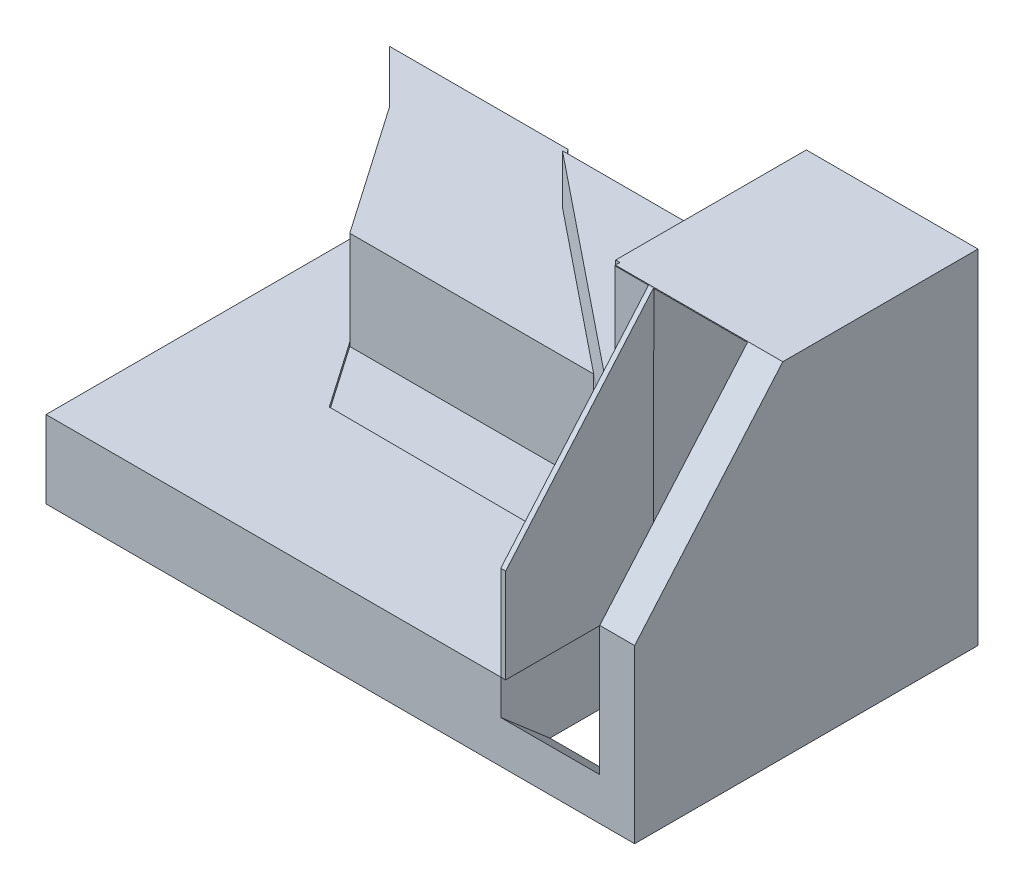
from build123d import *

# Parameters (mm, degrees)
SKETCH1_W           = 120
SKETCH1_H           = 70
BOSS_EXTRUDE1_DEPTH = 70
CUT_EXTRUDE1_DEPTH  = 150
SKETCH5_W           = 20.177747719
SKETCH5_H           = 66.048531366
CUT_EXTRUDE3_DEPTH  = 150
CUT_EXTRUDE4_DEPTH  = 25
CUT_EXTRUDE5_DEPTH  = 35
BOSS_EXTRUDE2_DEPTH = 35
CUT_EXTRUDE6_DEPTH  = 55
SKETCH14_W          = 58.303279042
SKETCH14_H          = 35.625039804
CUT_EXTRUDE7_DEPTH  = 1
BOSS_EXTRUDE5_DEPTH = 1
CUT_EXTRUDE9_DEPTH  = 20
CUT_EXTRUDE10_DEPTH = 20


with BuildPart() as part:
    # Sketch1 → Boss-Extrude1 (new body)
    with BuildSketch(Plane.XY):
        with Locations((10.120481928, 29.21686747)):
            Rectangle(SKETCH1_W, SKETCH1_H)
    extrude(amount=BOSS_EXTRUDE1_DEPTH)

    # Sketch3 → Cut-Extrude1 (cut)
    with BuildSketch(Plane(origin=(70.120481928, 0, 0), x_dir=(0, 0, -1), z_dir=(1, 0, 0))):
        Polygon((-39.794288679, 64.21686747), (-70, 29.21686747), (-70, 64.21686747), align=None)
    extrude(amount=-CUT_EXTRUDE1_DEPTH, mode=Mode.SUBTRACT)

    # Sketch5 → Cut-Extrude3 (cut)
    with BuildSketch(Plane(origin=(0, 47.095410713, 54.570453827), x_dir=(1, 0, 0), z_dir=(0, 0.653352699, 0.757053665))):
        with Locations((52.91919907, -10.542758773)):
            Rectangle(SKETCH5_W, SKETCH5_H)
    extrude(amount=-CUT_EXTRUDE3_DEPTH, mode=Mode.SUBTRACT)

    # Sketch6 → Cut-Extrude4 (cut)
    with BuildSketch(Plane(origin=(0, 64.21686747, 0), x_dir=(1, 0, 0), z_dir=(0, 1, 0))):
        Polygon((35.120481928, 0), (-14.879518072, 0), (35.120481928, -40), align=None)
    extrude(amount=-CUT_EXTRUDE4_DEPTH, mode=Mode.SUBTRACT)

    # Sketch9 → Cut-Extrude5 (cut)
    with BuildSketch(Plane(origin=(0, 64.21686747, 0), x_dir=(1, 0, 0), z_dir=(0, 1, 0))):
        Polygon((12.260999006, -39.794288679), (-22.324601561, -39.794288679), (-49.879518072, 0), (-58.507323934, 12.460113859), (-30.081695552, 12.460113859), (34.863342776, -39.794288679), align=None)
    extrude(amount=-CUT_EXTRUDE5_DEPTH, mode=Mode.SUBTRACT)

    # Sketch10 → Boss-Extrude2 (add)
    with BuildSketch(Plane(origin=(0, 29.21686747, 0), x_dir=(1, 0, 0), z_dir=(0, 1, 0))):
        Polygon((-49.879518072, 0), (-60.681640724, 10.802122652), (-24.289355103, 10.802122652), (-14.595487063, 0), align=None)
    extrude(amount=-BOSS_EXTRUDE2_DEPTH)

    # Sketch13 → Cut-Extrude6 (cut)
    with BuildSketch(Plane(origin=(0, 65, 0), x_dir=(1, 0, 0), z_dir=(0, 1, 0))):
        Polygon((-49.879518072, 0), (-49.879518072, -70), (42.83032521, -70), (42.83032521, -39.882100619), (-22.324601561, -39.794288679), align=None)
    extrude(amount=-CUT_EXTRUDE6_DEPTH, mode=Mode.SUBTRACT)

    # Sketch14 → Cut-Extrude7 (cut)
    with BuildSketch(Plane(origin=(-0.053672831, 0, 39.824304114), x_dir=(0.999999092, 0, 0.001347739), z_dir=(-0.001347739, 0, 0.999999092))):
        with Locations((6.880690565, 46.404347568)):
            Rectangle(SKETCH14_W, SKETCH14_H)
    extrude(amount=-CUT_EXTRUDE7_DEPTH, mode=Mode.SUBTRACT)

    # Sketch17 → Cut-Extrude9 (cut)
    with BuildSketch(Plane(origin=(0, 29.21686747, 0), x_dir=(1, 0, 0), z_dir=(0, 1, 0))):
        Polygon((18.016338489, -26.239286383), (35.120481928, -40), (18.016338489, -40), align=None)
    extrude(amount=-CUT_EXTRUDE9_DEPTH, mode=Mode.SUBTRACT)

    # Sketch18 → Cut-Extrude10 (cut)
    with BuildSketch(Plane(origin=(0, 29.21686747, 0), x_dir=(1, 0, 0), z_dir=(0, 1, 0))):
        Polygon((18.016338489, -40), (-22.324601561, -39.794288679), (-31.710545347, -26.239286383), (18.016338489, -26.239286383), align=None)
    extrude(amount=-CUT_EXTRUDE10_DEPTH, mode=Mode.SUBTRACT)


with BuildPart() as body_2:
    # Sketch16 → Boss-Extrude5 (new body)
    with BuildSketch(Plane(origin=(42.83032521, 0, 0), x_dir=(0, 0, -1), z_dir=(1, 0, 0))):
        Polygon((-39.794288679, 64.21686747), (-70, 29.21686747), (-70, 11.71686747), (-70, 10), (-39.882100619, 10), align=None)
    extrude(amount=BOSS_EXTRUDE5_DEPTH)


solid = Compound([part.part, body_2.part])
